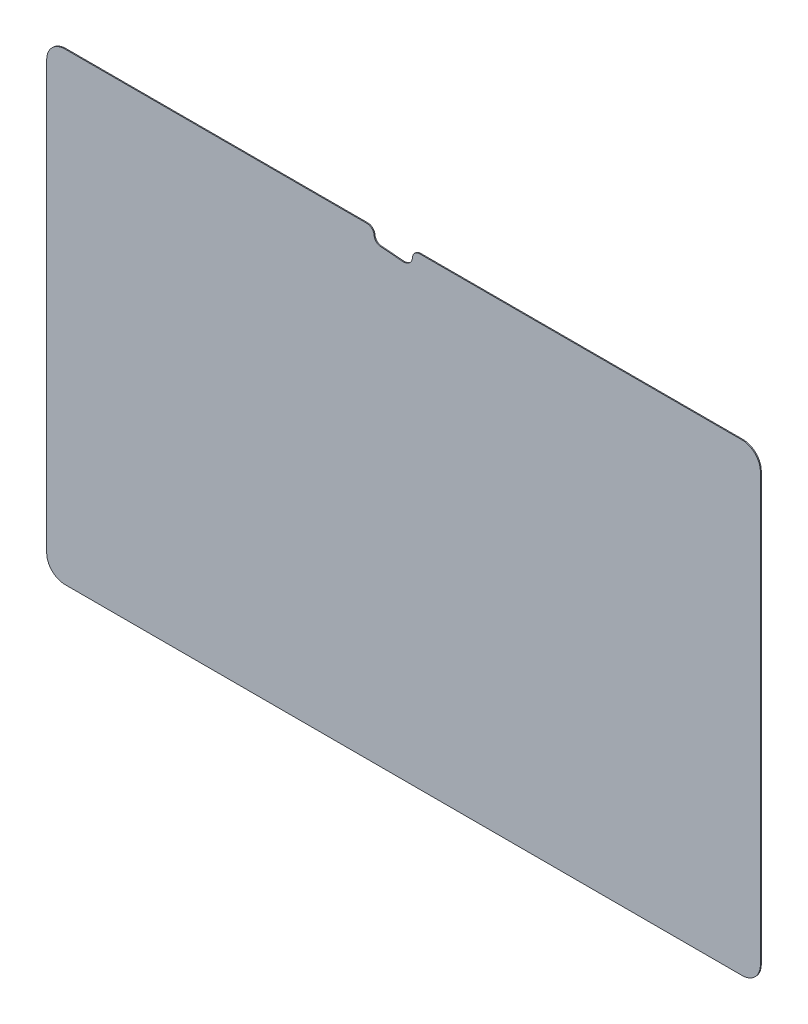
from build123d import *

# Parameters (mm, degrees)
SKETCH1_W           = 252.0188
SKETCH1_H           = 163.7792
BOSS_EXTRUDE1_DEPTH = 0.3302
FILLET1_R           = 6.4516
CUT_EXTRUDE1_REACH  = 2.33
FILLET2_R           = 2.54


with BuildPart() as part:
    # Sketch1 → Boss-Extrude1 (new body)
    with BuildSketch(Plane.XY):
        Rectangle(SKETCH1_W, SKETCH1_H)
    extrude(amount=BOSS_EXTRUDE1_DEPTH)

    # Fillet1
    fillet1_edges = [part.edges().sort_by_distance(p)[0] for p in [
        (-126.0094, 81.8896, 0.1651),
        (126.0094, 81.8896, 0.1651),
        (126.0094, -81.8896, 0.1651),
        (-126.0094, -81.8896, 0.1651),
    ]]
    fillet(fillet1_edges, radius=FILLET1_R)

    # Sketch2 → Cut-Extrude1 (cut, up to next)
    with BuildSketch(Plane.XY.offset(0.3302), mode=Mode.PRIVATE) as cut_extrude1_sk1:
        with BuildLine():
            Line((-0.256043801, 76.565941373), (-8.078834123, 77.198873099))
            ThreePointArc((-8.078834123, 77.198873099), (-10.342970739, 79.134143092), (-9.21202344, 81.8896))
            Line((-9.21202344, 81.8896), (2.32795304, 81.8896))
            ThreePointArc((2.32795304, 81.8896), (2.856318254, 78.344202786), (-0.256043801, 76.565941373))
        make_face()
    cut_extrude1_tool1 = extrude(cut_extrude1_sk1.sketch, amount=-CUT_EXTRUDE1_REACH, mode=Mode.PRIVATE) & part.part
    add(cut_extrude1_tool1.solids().sort_by_distance((-3.468572, 79.429451, 0.3302))[0], mode=Mode.SUBTRACT)

    # Fillet2
    fillet2_edges = [part.edges().sort_by_distance(p)[0] for p in [
        (2.32795304, 81.8896, 0.1651),
        (-9.21202344, 81.8896, 0.1651),
    ]]
    fillet(fillet2_edges, radius=FILLET2_R)


solid = part.part
